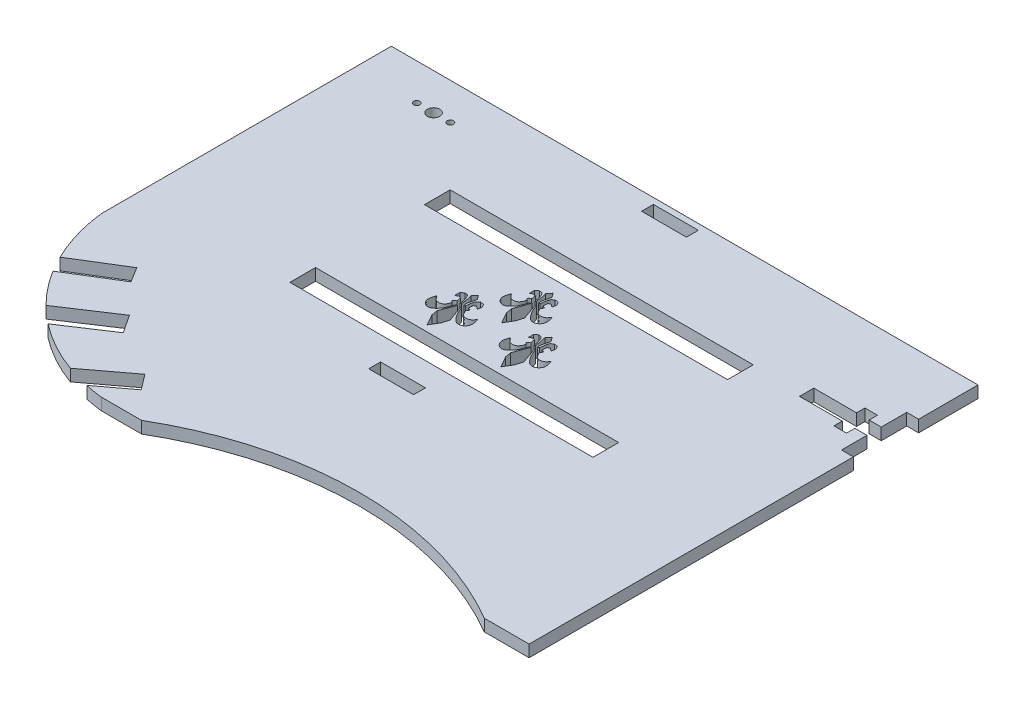
from build123d import *

# Parameters (mm, degrees)
SKETCH3_W               = 160
SKETCH3_H               = 120
BOSS_EXTRUDE1_DEPTH     = 3.175
SKETCH4_W               = 3.175
SKETCH4_H               = 17.435105301
CUT_EXTRUDE1_DEPTH      = 4.175
CUT_EXTRUDE2_DEPTH      = 4.175
SKETCH6_W               = 12
SKETCH6_H               = 3.175
CUT_EXTRUDE3_DEPTH      = 4.175
SKETCH8_W               = 3.17
SKETCH8_H               = 120
CUT_EXTRUDE4_DEPTH      = 4.175
SKETCH10_W              = 3.175
SKETCH10_H              = 3.175
CUT_EXTRUDE6_DEPTH      = 3.175
SKETCH11_W              = 3.175
SKETCH11_H              = 3.175
BOSS_EXTRUDE2_DEPTH     = 3.175
SKETCH14_W              = 12
SKETCH14_H              = 3.18
CUT_EXTRUDE8_DEPTH      = 4.175
CUT_EXTRUDE9_DEPTH      = 1
CUT_EXTRUDE9_DEPTH_BACK = 4.175
CUT_EXTRUDE10_DEPTH     = 3.18
CUT_EXTRUDE11_DEPTH     = 3.18
SKETCH22_W              = 81.025514908
SKETCH22_H              = 6.858687775
SKETCH22_H_2            = 6.86
CUT_EXTRUDE12_DEPTH     = 3.18
CUT_EXTRUDE13_DEPTH     = 3.18
SKETCH24_R              = 0.83
CUT_EXTRUDE14_DEPTH     = 10
SKETCH25_R              = 1.655978765
CUT_EXTRUDE15_DEPTH     = 80.772


with BuildPart() as part:
    # Sketch3 → Boss-Extrude1 (new body)
    with BuildSketch(Plane(origin=(0, 0, 0), x_dir=(1, 0, 0), z_dir=(0, 1, 0))):
        with Locations((80, -60)):
            Rectangle(SKETCH3_W, SKETCH3_H)
    extrude(amount=BOSS_EXTRUDE1_DEPTH)

    # Sketch4 → Cut-Extrude1 (cut, through all)
    with BuildSketch(Plane(origin=(0, 0, 0), x_dir=(-1, 0, 0), z_dir=(0, -1, 0))):
        with Locations((-158.4125, -24.593852358)):
            Rectangle(SKETCH4_W, SKETCH4_H)
    extrude(amount=-CUT_EXTRUDE1_DEPTH, mode=Mode.SUBTRACT)

    # Sketch5 → Cut-Extrude2 (cut, through all)
    with BuildSketch(Plane.XZ):
        Polygon((156.825, 26.498852357), (156.825, 22.688852357), (153.573768173, 22.688852357), (153.573768173, 20.453652357), (150.221, 20.453652357), (150.221, 22.688852357), (138.791, 22.688852357), (138.791, 26.498852357), (150.221, 26.498852357), (150.221, 28.734052357), (153.573768173, 28.734052357), (153.573768173, 26.498852357), align=None)
    extrude(amount=-CUT_EXTRUDE2_DEPTH, mode=Mode.SUBTRACT)

    # Sketch6 → Cut-Extrude3 (cut, through all)
    with BuildSketch(Plane(origin=(0, 3.175, 0), x_dir=(1, 0, 0), z_dir=(0, 1, 0))):
        with Locations((84, -3.177552545)):
            Rectangle(SKETCH6_W, SKETCH6_H)
    extrude(amount=-CUT_EXTRUDE3_DEPTH, mode=Mode.SUBTRACT)

    # Sketch8 → Cut-Extrude4 (cut, through all)
    with BuildSketch(Plane(origin=(0, 3.175, 0), x_dir=(1, 0, 0), z_dir=(0, 1, 0))):
        with Locations((1.585, -60)):
            Rectangle(SKETCH8_W, SKETCH8_H)
    extrude(amount=-CUT_EXTRUDE4_DEPTH, mode=Mode.SUBTRACT)

    # Sketch10 → Cut-Extrude6 (cut)
    with BuildSketch(Plane(origin=(0, 3.175, 0), x_dir=(1, 0, 0), z_dir=(0, 1, 0))):
        with Locations((76.4125, -3.177552545)):
            Rectangle(SKETCH10_W, SKETCH10_H)
    extrude(amount=-CUT_EXTRUDE6_DEPTH, mode=Mode.SUBTRACT)

    # Sketch11 → Boss-Extrude2 (add)
    with BuildSketch(Plane.ZY.offset(-90)):
        with Locations((3.177552545, 1.5875)):
            Rectangle(SKETCH11_W, SKETCH11_H)
    extrude(amount=BOSS_EXTRUDE2_DEPTH)

    # Sketch14 → Cut-Extrude8 (cut, through all)
    with BuildSketch(Plane(origin=(0, 3.175, 0), x_dir=(1, 0, 0), z_dir=(0, 1, 0))):
        with Locations((80.825, -76.121511289)):
            Rectangle(SKETCH14_W, SKETCH14_H)
    extrude(amount=-CUT_EXTRUDE8_DEPTH, mode=Mode.SUBTRACT)

    # Sketch18 → Cut-Extrude9 (cut, two sides)
    with BuildSketch(Plane(origin=(0, 3.175, 0), x_dir=(1, 0, 0), z_dir=(0, 1, 0))) as cut_extrude9_sk:
        with BuildLine():
            Line((3.17, -120), (45.627652889, -120))
            ThreePointArc((45.627652889, -120), (17.010977531, -106.159022469), (3.17, -77.542347111))
            Line((3.17, -77.542347111), (3.17, -120))
        make_face()
    extrude(amount=CUT_EXTRUDE9_DEPTH, mode=Mode.SUBTRACT)
    extrude(cut_extrude9_sk.sketch, amount=-CUT_EXTRUDE9_DEPTH_BACK, mode=Mode.SUBTRACT)

    # Sketch20 → Cut-Extrude10 (cut)
    with BuildSketch(Plane(origin=(0, 3.175, 0), x_dir=(1, 0, 0), z_dir=(0, 1, 0))):
        Polygon((10.011232474, -97.293572395), (22.920901511, -89.355856032), (20.42596132, -85.298158494), (7.516292283, -93.235874857), align=None)
        Polygon((17.010977531, -106.159022469), (30.452466209, -97.293572395), (33.670458106, -102.172580373), (20.228969428, -111.038030448), align=None)
        Polygon((34.806657091, -117.45740808), (46.189284418, -108.886802916), (49.274109143, -112.983761012), (37.891481816, -121.554366177), align=None)
    extrude(amount=-CUT_EXTRUDE10_DEPTH, mode=Mode.SUBTRACT)

    # Sketch21 → Cut-Extrude11 (cut)
    with BuildSketch(Plane(origin=(0, 3.175, 0), x_dir=(1, 0, 0), z_dir=(0, 1, 0))):
        with BuildLine():
            Line((481.322028139, -315.153099991), (148.033410765, -120))
            ThreePointArc((148.033410765, -120), (102.224970687, -107.57533056), (56.416530609, -120))
            Line((56.416530609, -120), (-276.872086765, -315.153099991))
            Line((-276.872086765, -315.153099991), (-276.872086765, -1087.593479327))
            Line((-276.872086765, -1087.593479327), (481.322028139, -1087.593479327))
            Line((481.322028139, -1087.593479327), (481.322028139, -315.153099991))
        make_face()
    extrude(amount=-CUT_EXTRUDE11_DEPTH, mode=Mode.SUBTRACT)

    # Sketch22 → Cut-Extrude12 (cut)
    with BuildSketch(Plane(origin=(0, 3.175, 0), x_dir=(1, 0, 0), z_dir=(0, 1, 0))):
        with Locations((84.792947212, -64.796382292)):
            Rectangle(SKETCH22_W, SKETCH22_H)
        with Locations((84.792947212, -28.821709785)):
            Rectangle(SKETCH22_W, SKETCH22_H_2)
    extrude(amount=-CUT_EXTRUDE12_DEPTH, mode=Mode.SUBTRACT)

    # Sketch23 → Cut-Extrude13 (cut)
    with BuildSketch(Plane(origin=(0, 3.175, 0), x_dir=(1, 0, 0), z_dir=(0, 1, 0))):
        with BuildLine():
            Line((92.040417593, -59.591635437), (90.350166764, -56.601191664))
            Line((90.350166764, -56.601191664), (90.090128175, -55.008455307))
            Line((90.090128175, -55.008455307), (91.552845238, -51.010362001))
            add(Edge.make_bspline(
                [(91.552845238, -51.010362001), (91.433660885, -51.064536707), (91.256267279, -51.057033429), (91.195292178, -51.172886119), (90.808267546, -51.90823292), (90.689834748, -52.774050109), (90.252652294, -53.480728597), (89.885655321, -54.073956579), (89.392536165, -54.606464459), (88.822440054, -55.008455307), (88.513150163, -55.226544333), (88.088992408, -55.339557317), (87.717276051, -55.268493896), (87.291986987, -55.187188633), (86.882599473, -54.924001881), (86.612112048, -54.5858926), (86.331646339, -54.235310464), (86.167019037, -53.767057858), (86.157044517, -53.318204478), (86.14443269, -52.750672253), (86.417083106, -52.213040475), (86.547102401, -51.660458474)],
                knots=[0, 0, 0, 0, 1, 1, 1, 2, 2, 2, 3, 3, 3, 4, 4, 4, 5, 5, 5, 6, 6, 6, 7, 7, 7, 7], degree=3))
            Line((86.547102401, -51.660458474), (86.677121695, -51.62795365))
            add(Edge.make_bspline(
                [(86.677121695, -51.62795365), (87.002169931, -51.98550671), (87.221318587, -52.482016111), (87.652266404, -52.70061283), (88.029614545, -52.892021307), (88.517953599, -52.897622781), (88.919954525, -52.765622477), (89.299585453, -52.640967545), (89.600138024, -52.312279983), (89.830089586, -51.98550671), (90.027271425, -51.70530094), (90.046788411, -51.335410238), (90.155137823, -51.010362001)],
                knots=[0, 0, 0, 0, 1, 1, 1, 2, 2, 2, 3, 3, 3, 4, 4, 4, 4], degree=3))
            Line((90.155137823, -51.010362001), (89.732575116, -50.587799294))
            add(Edge.make_bspline(
                [(89.732575116, -50.587799294), (89.851759469, -50.446945059), (89.941747705, -50.274909108), (90.090128175, -50.165236587), (90.200342422, -50.083773884), (90.350166764, -50.078557058), (90.480186059, -50.035217293)],
                knots=[0, 0, 0, 0, 1, 1, 1, 2, 2, 2, 2], degree=3))
            Line((90.480186059, -50.035217293), (90.252652294, -48.832538819))
            add(Edge.make_bspline(
                [(90.252652294, -48.832538819), (90.003448646, -48.800033995), (89.746686344, -48.665982921), (89.50504135, -48.735024348), (89.252846931, -48.807079896), (89.093313584, -49.060072584), (88.887449701, -49.222596702)],
                knots=[0, 0, 0, 0, 1, 1, 1, 2, 2, 2, 2], degree=3))
            Line((88.887449701, -49.222596702), (88.919954525, -47.694869992))
            Line((88.919954525, -47.694869992), (89.700070292, -47.109783167))
            add(Edge.make_bspline(
                [(89.700070292, -47.109783167), (89.970943822, -47.174792814), (90.315715346, -47.107836573), (90.512690882, -47.304812109), (90.84848667, -47.640607896), (91.014153381, -48.121472998), (91.162787355, -48.57250023), (91.331736227, -49.085172668), (91.357816297, -49.634324468), (91.455330767, -50.165236587)],
                knots=[0, 0, 0, 0, 1, 1, 1, 2, 2, 2, 3, 3, 3, 3], degree=3))
            Line((91.455330767, -50.165236587), (91.715369356, -50.035217293))
            add(Edge.make_bspline(
                [(91.715369356, -50.035217293), (91.639524768, -49.450130468), (91.591760514, -48.860713741), (91.487835591, -48.279956817), (91.407290454, -47.829851641), (91.271136767, -47.391491638), (91.162787355, -46.947259049)],
                knots=[0, 0, 0, 0, 1, 1, 1, 2, 2, 2, 2], degree=3))
            Line((91.162787355, -46.947259049), (92.040417593, -45.874599869))
            Line((92.040417593, -45.874599869), (92.885543007, -46.979763872))
            add(Edge.make_bspline(
                [(92.885543007, -46.979763872), (92.777193595, -47.445666344), (92.671877484, -47.912284659), (92.560494771, -48.377471288), (92.487677503, -48.681590463), (92.349992883, -48.975355261), (92.332961005, -49.287606349), (92.316853875, -49.582903731), (92.419640535, -49.872693175), (92.4629803, -50.165236587)],
                knots=[0, 0, 0, 0, 1, 1, 1, 2, 2, 2, 3, 3, 3, 3], degree=3))
            Line((92.4629803, -50.165236587), (92.755523712, -50.035217293))
            add(Edge.make_bspline(
                [(92.755523712, -50.035217293), (92.885543007, -49.309276232), (92.875677077, -48.543722743), (93.145581596, -47.85739411), (93.271788678, -47.536467529), (93.643988891, -47.380656697), (93.893192539, -47.14228799)],
                knots=[0, 0, 0, 0, 1, 1, 1, 2, 2, 2, 2], degree=3))
            Line((93.893192539, -47.14228799), (94.8033276, -47.272307285))
            add(Edge.make_bspline(
                [(94.8033276, -47.272307285), (94.955016777, -47.564850698), (95.209512224, -47.824051475), (95.258395131, -48.149937523), (95.31204007, -48.507570449), (95.150045719, -48.865043642), (95.095871013, -49.222596702)],
                knots=[0, 0, 0, 0, 1, 1, 1, 2, 2, 2, 2], degree=3))
            Line((95.095871013, -49.222596702), (94.34826007, -48.670014701))
            Line((94.34826007, -48.670014701), (93.763173245, -48.93005329))
            Line((93.763173245, -48.93005329), (93.665658774, -50.165236587))
            Line((93.665658774, -50.165236587), (94.283250422, -50.392770353))
            add(Edge.make_bspline(
                [(94.283250422, -50.392770353), (94.229075716, -50.566129412), (94.207232046, -50.753144622), (94.120726304, -50.91284753), (94.062341913, -51.0206341), (93.947367245, -51.08620659), (93.860687715, -51.172886119)],
                knots=[0, 0, 0, 0, 1, 1, 1, 2, 2, 2, 2], degree=3))
            add(Edge.make_bspline(
                [(93.860687715, -51.172886119), (94.153231128, -51.62795365), (94.329041742, -52.18430758), (94.738317953, -52.538088712), (95.010799127, -52.773623286), (95.418483529, -52.842060339), (95.778472309, -52.830632124), (96.134694899, -52.81932347), (96.492114255, -52.674528706), (96.786121841, -52.473079064), (97.096390872, -52.260487321), (97.284529137, -51.909662122), (97.533732785, -51.62795365)],
                knots=[0, 0, 0, 0, 1, 1, 1, 2, 2, 2, 3, 3, 3, 4, 4, 4, 4], degree=3))
            add(Edge.make_bspline(
                [(97.533732785, -51.62795365), (97.663752079, -52.234710358), (97.950172367, -52.828253834), (97.923790668, -53.448223773), (97.904797811, -53.894555923), (97.710793086, -54.358945611), (97.40371349, -54.68340707), (97.097266769, -55.007199832), (96.645352124, -55.231974681), (96.201035016, -55.268493896), (95.791259692, -55.302174059), (95.346074128, -55.142426701), (95.030861366, -54.878436012), (94.445792267, -54.388440642), (93.991666711, -53.746038214), (93.600649126, -53.090670713), (93.215028431, -52.444348702), (93.015562301, -51.703798239), (92.723018889, -51.010362001)],
                knots=[0, 0, 0, 0, 1, 1, 1, 2, 2, 2, 3, 3, 3, 4, 4, 4, 5, 5, 5, 6, 6, 6, 6], degree=3))
            Line((92.723018889, -51.010362001), (92.495485123, -51.140381296))
            Line((92.495485123, -51.140381296), (93.99070701, -55.39851319))
            Line((93.99070701, -55.39851319), (93.405620185, -57.316297784))
            Line((93.405620185, -57.316297784), (92.040417593, -59.591635437))
        make_face()
        with BuildLine():
            Line((72.472458803, -59.743861952), (70.782207974, -56.753418179))
            Line((70.782207974, -56.753418179), (70.522169385, -55.160681822))
            Line((70.522169385, -55.160681822), (71.984886448, -51.162588516))
            add(Edge.make_bspline(
                [(71.984886448, -51.162588516), (71.865702095, -51.216763223), (71.688308489, -51.209259944), (71.627333388, -51.325112635), (71.240308756, -52.060459436), (71.121875958, -52.926276624), (70.684693503, -53.632955112), (70.317696531, -54.226183094), (69.824577375, -54.758690975), (69.254481264, -55.160681822), (68.945191373, -55.378770848), (68.521033618, -55.491783832), (68.149317261, -55.420720411), (67.724028197, -55.339415149), (67.314640683, -55.076228396), (67.044153258, -54.738119115), (66.763687549, -54.387536979), (66.599060247, -53.919284374), (66.589085727, -53.470430994), (66.5764739, -52.902898768), (66.849124316, -52.36526699), (66.979143611, -51.812684989)],
                knots=[0, 0, 0, 0, 1, 1, 1, 2, 2, 2, 3, 3, 3, 4, 4, 4, 5, 5, 5, 6, 6, 6, 7, 7, 7, 7], degree=3))
            Line((66.979143611, -51.812684989), (67.109162905, -51.780180165))
            add(Edge.make_bspline(
                [(67.109162905, -51.780180165), (67.434211141, -52.137733225), (67.653359797, -52.634242626), (68.084307614, -52.852839345), (68.461655755, -53.044247822), (68.949994809, -53.049849296), (69.351995735, -52.917848992), (69.731626663, -52.79319406), (70.032179234, -52.464506498), (70.262130796, -52.137733225), (70.459312635, -51.857527455), (70.478829621, -51.487636753), (70.587179033, -51.162588516)],
                knots=[0, 0, 0, 0, 1, 1, 1, 2, 2, 2, 3, 3, 3, 4, 4, 4, 4], degree=3))
            Line((70.587179033, -51.162588516), (70.164616326, -50.740025809))
            add(Edge.make_bspline(
                [(70.164616326, -50.740025809), (70.283800679, -50.599171574), (70.373788915, -50.427135624), (70.522169385, -50.317463102), (70.632383632, -50.236000399), (70.782207974, -50.230783573), (70.912227269, -50.187443808)],
                knots=[0, 0, 0, 0, 1, 1, 1, 2, 2, 2, 2], degree=3))
            Line((70.912227269, -50.187443808), (70.684693503, -48.984765334))
            add(Edge.make_bspline(
                [(70.684693503, -48.984765334), (70.435489856, -48.95226051), (70.178727554, -48.818209436), (69.93708256, -48.887250863), (69.684888141, -48.959306411), (69.525354794, -49.212299099), (69.319490911, -49.374823217)],
                knots=[0, 0, 0, 0, 1, 1, 1, 2, 2, 2, 2], degree=3))
            Line((69.319490911, -49.374823217), (69.351995735, -47.847096507))
            Line((69.351995735, -47.847096507), (70.132111502, -47.262009682))
            add(Edge.make_bspline(
                [(70.132111502, -47.262009682), (70.402985032, -47.327019329), (70.747756556, -47.260063088), (70.944732092, -47.457038624), (71.28052788, -47.792834411), (71.446194591, -48.273699513), (71.594828565, -48.724726745), (71.763777437, -49.237399183), (71.789857507, -49.786550983), (71.887371977, -50.317463102)],
                knots=[0, 0, 0, 0, 1, 1, 1, 2, 2, 2, 3, 3, 3, 3], degree=3))
            Line((71.887371977, -50.317463102), (72.147410566, -50.187443808))
            add(Edge.make_bspline(
                [(72.147410566, -50.187443808), (72.071565978, -49.602356983), (72.023801724, -49.012940256), (71.919876801, -48.432183332), (71.839331664, -47.982078156), (71.703177977, -47.543718153), (71.594828565, -47.099485564)],
                knots=[0, 0, 0, 0, 1, 1, 1, 2, 2, 2, 2], degree=3))
            Line((71.594828565, -47.099485564), (72.472458803, -46.026826384))
            Line((72.472458803, -46.026826384), (73.317584217, -47.131990388))
            add(Edge.make_bspline(
                [(73.317584217, -47.131990388), (73.209234805, -47.597892859), (73.103918694, -48.064511175), (72.992535981, -48.529697803), (72.919718713, -48.833816978), (72.782034093, -49.127581776), (72.765002215, -49.439832865), (72.748895085, -49.735130247), (72.851681745, -50.02491969), (72.89502151, -50.317463102)],
                knots=[0, 0, 0, 0, 1, 1, 1, 2, 2, 2, 3, 3, 3, 3], degree=3))
            Line((72.89502151, -50.317463102), (73.187564922, -50.187443808))
            add(Edge.make_bspline(
                [(73.187564922, -50.187443808), (73.317584217, -49.461502747), (73.307718287, -48.695949258), (73.577622806, -48.009620625), (73.703829888, -47.688694044), (74.076030101, -47.532883212), (74.325233749, -47.294514506)],
                knots=[0, 0, 0, 0, 1, 1, 1, 2, 2, 2, 2], degree=3))
            Line((74.325233749, -47.294514506), (75.23536881, -47.4245338))
            add(Edge.make_bspline(
                [(75.23536881, -47.4245338), (75.387057987, -47.717077213), (75.641553434, -47.97627799), (75.690436341, -48.302164038), (75.74408128, -48.659796964), (75.582086929, -49.017270158), (75.527912223, -49.374823217)],
                knots=[0, 0, 0, 0, 1, 1, 1, 2, 2, 2, 2], degree=3))
            Line((75.527912223, -49.374823217), (74.78030128, -48.822241216))
            Line((74.78030128, -48.822241216), (74.195214455, -49.082279805))
            Line((74.195214455, -49.082279805), (74.097699984, -50.317463102))
            Line((74.097699984, -50.317463102), (74.715291632, -50.544996868))
            add(Edge.make_bspline(
                [(74.715291632, -50.544996868), (74.661116926, -50.718355927), (74.639273256, -50.905371138), (74.552767514, -51.065074046), (74.494383123, -51.172860615), (74.379408455, -51.238433105), (74.292728925, -51.325112635)],
                knots=[0, 0, 0, 0, 1, 1, 1, 2, 2, 2, 2], degree=3))
            add(Edge.make_bspline(
                [(74.292728925, -51.325112635), (74.585272338, -51.780180165), (74.761082952, -52.336534095), (75.170359163, -52.690315227), (75.442840337, -52.925849801), (75.850524739, -52.994286854), (76.210513519, -52.982858639), (76.566736109, -52.971549986), (76.924155465, -52.826755222), (77.218163051, -52.625305579), (77.528432082, -52.412713836), (77.716570347, -52.061888637), (77.965773995, -51.780180165)],
                knots=[0, 0, 0, 0, 1, 1, 1, 2, 2, 2, 3, 3, 3, 4, 4, 4, 4], degree=3))
            add(Edge.make_bspline(
                [(77.965773995, -51.780180165), (78.095793289, -52.386936873), (78.382213577, -52.980480349), (78.355831878, -53.600450288), (78.336839021, -54.046782438), (78.142834296, -54.511172126), (77.8357547, -54.835633586), (77.529307979, -55.159426347), (77.077393334, -55.384201196), (76.633076226, -55.420720411), (76.223300902, -55.454400574), (75.778115338, -55.294653216), (75.462902576, -55.030662527), (74.877833477, -54.540667157), (74.423707921, -53.898264729), (74.032690336, -53.242897228), (73.647069641, -52.596575217), (73.447603511, -51.856024754), (73.155060099, -51.162588516)],
                knots=[0, 0, 0, 0, 1, 1, 1, 2, 2, 2, 3, 3, 3, 4, 4, 4, 5, 5, 5, 6, 6, 6, 6], degree=3))
            Line((73.155060099, -51.162588516), (72.927526333, -51.292607811))
            Line((72.927526333, -51.292607811), (74.42274822, -55.550739705))
            Line((74.42274822, -55.550739705), (73.837661395, -57.468524299))
            Line((73.837661395, -57.468524299), (72.472458803, -59.743861952))
        make_face()
        with BuildLine():
            Line((81.965210871, -49.28764759), (80.274960043, -46.297203817))
            Line((80.274960043, -46.297203817), (80.014921454, -44.70446746))
            Line((80.014921454, -44.70446746), (81.477638517, -40.706374154))
            add(Edge.make_bspline(
                [(81.477638517, -40.706374154), (81.358454164, -40.76054886), (81.181060558, -40.753045582), (81.120085457, -40.868898272), (80.733060825, -41.604245073), (80.614628027, -42.470062262), (80.177445572, -43.176740749), (79.8104486, -43.769968732), (79.317329444, -44.302476612), (78.747233333, -44.70446746), (78.437943442, -44.922556486), (78.013785687, -45.03556947), (77.64206933, -44.964506049), (77.216780266, -44.883200786), (76.807392752, -44.620014034), (76.536905327, -44.281904752), (76.256439618, -43.931322617), (76.091812316, -43.463070011), (76.081837796, -43.014216631), (76.069225969, -42.446684406), (76.341876385, -41.909052628), (76.47189568, -41.356470627)],
                knots=[0, 0, 0, 0, 1, 1, 1, 2, 2, 2, 3, 3, 3, 4, 4, 4, 5, 5, 5, 6, 6, 6, 7, 7, 7, 7], degree=3))
            Line((76.47189568, -41.356470627), (76.601914974, -41.323965803))
            add(Edge.make_bspline(
                [(76.601914974, -41.323965803), (76.92696321, -41.681518863), (77.146111866, -42.178028264), (77.577059683, -42.396624982), (77.954407824, -42.58803346), (78.442746877, -42.593634934), (78.844747804, -42.46163463), (79.224378732, -42.336979698), (79.524931303, -42.008292136), (79.754882865, -41.681518863), (79.952064704, -41.401313093), (79.971581689, -41.03142239), (80.079931101, -40.706374154)],
                knots=[0, 0, 0, 0, 1, 1, 1, 2, 2, 2, 3, 3, 3, 4, 4, 4, 4], degree=3))
            Line((80.079931101, -40.706374154), (79.657368394, -40.283811447))
            add(Edge.make_bspline(
                [(79.657368394, -40.283811447), (79.776552748, -40.142957211), (79.866540984, -39.970921261), (80.014921454, -39.86124874), (80.1251357, -39.779786036), (80.274960043, -39.77456921), (80.404979338, -39.731229446)],
                knots=[0, 0, 0, 0, 1, 1, 1, 2, 2, 2, 2], degree=3))
            Line((80.404979338, -39.731229446), (80.177445572, -38.528550972))
            add(Edge.make_bspline(
                [(80.177445572, -38.528550972), (79.928241925, -38.496046148), (79.671479623, -38.361995074), (79.429834629, -38.431036501), (79.17764021, -38.503092049), (79.018106863, -38.756084737), (78.81224298, -38.918608855)],
                knots=[0, 0, 0, 0, 1, 1, 1, 2, 2, 2, 2], degree=3))
            Line((78.81224298, -38.918608855), (78.844747804, -37.390882145))
            Line((78.844747804, -37.390882145), (79.624863571, -36.80579532))
            add(Edge.make_bspline(
                [(79.624863571, -36.80579532), (79.895737101, -36.870804967), (80.240508625, -36.803848725), (80.437484161, -37.000824261), (80.773279949, -37.336620049), (80.93894666, -37.817485151), (81.087580634, -38.268512383), (81.256529505, -38.781184821), (81.282609575, -39.330336621), (81.380124046, -39.86124874)],
                knots=[0, 0, 0, 0, 1, 1, 1, 2, 2, 2, 3, 3, 3, 3], degree=3))
            Line((81.380124046, -39.86124874), (81.640162635, -39.731229446))
            add(Edge.make_bspline(
                [(81.640162635, -39.731229446), (81.564318047, -39.14614262), (81.516553793, -38.556725894), (81.41262887, -37.97596897), (81.332083733, -37.525863794), (81.195930046, -37.087503791), (81.087580634, -36.643271202)],
                knots=[0, 0, 0, 0, 1, 1, 1, 2, 2, 2, 2], degree=3))
            Line((81.087580634, -36.643271202), (81.965210871, -35.570612022))
            Line((81.965210871, -35.570612022), (82.810336286, -36.675776025))
            add(Edge.make_bspline(
                [(82.810336286, -36.675776025), (82.701986874, -37.141678497), (82.596670763, -37.608296812), (82.485288049, -38.073483441), (82.412470782, -38.377602616), (82.274786162, -38.671367414), (82.257754284, -38.983618502), (82.241647154, -39.278915884), (82.344433814, -39.568705327), (82.387773579, -39.86124874)],
                knots=[0, 0, 0, 0, 1, 1, 1, 2, 2, 2, 3, 3, 3, 3], degree=3))
            Line((82.387773579, -39.86124874), (82.680316991, -39.731229446))
            add(Edge.make_bspline(
                [(82.680316991, -39.731229446), (82.810336286, -39.005288385), (82.800470356, -38.239734895), (83.070374875, -37.553406263), (83.196581957, -37.232479682), (83.56878217, -37.07666885), (83.817985818, -36.838300143)],
                knots=[0, 0, 0, 0, 1, 1, 1, 2, 2, 2, 2], degree=3))
            Line((83.817985818, -36.838300143), (84.728120879, -36.968319438))
            add(Edge.make_bspline(
                [(84.728120879, -36.968319438), (84.879810056, -37.26086285), (85.134305503, -37.520063628), (85.18318841, -37.845949676), (85.236833349, -38.203582602), (85.074838998, -38.561055795), (85.020664292, -38.918608855)],
                knots=[0, 0, 0, 0, 1, 1, 1, 2, 2, 2, 2], degree=3))
            Line((85.020664292, -38.918608855), (84.273053349, -38.366026854))
            Line((84.273053349, -38.366026854), (83.687966523, -38.626065442))
            Line((83.687966523, -38.626065442), (83.590452053, -39.86124874))
            Line((83.590452053, -39.86124874), (84.208043701, -40.088782505))
            add(Edge.make_bspline(
                [(84.208043701, -40.088782505), (84.153868995, -40.262141565), (84.132025325, -40.449156775), (84.045519583, -40.608859683), (83.987135191, -40.716646253), (83.872160524, -40.782218743), (83.785480994, -40.868898272)],
                knots=[0, 0, 0, 0, 1, 1, 1, 2, 2, 2, 2], degree=3))
            add(Edge.make_bspline(
                [(83.785480994, -40.868898272), (84.078024407, -41.323965803), (84.253835021, -41.880319733), (84.663111232, -42.234100864), (84.935592406, -42.469635439), (85.343276808, -42.538072492), (85.703265588, -42.526644277), (86.059488177, -42.515335623), (86.416907534, -42.370540859), (86.71091512, -42.169091217), (87.021184151, -41.956499474), (87.209322416, -41.605674274), (87.458526063, -41.323965803)],
                knots=[0, 0, 0, 0, 1, 1, 1, 2, 2, 2, 3, 3, 3, 4, 4, 4, 4], degree=3))
            add(Edge.make_bspline(
                [(87.458526063, -41.323965803), (87.588545358, -41.930722511), (87.874965646, -42.524265987), (87.848583947, -43.144235926), (87.829591089, -43.590568076), (87.635586364, -44.054957764), (87.328506769, -44.379419223), (87.022060048, -44.703211985), (86.570145402, -44.927986834), (86.125828295, -44.964506049), (85.716052971, -44.998186212), (85.270867407, -44.838438854), (84.955654645, -44.574448165), (84.370585546, -44.084452795), (83.91645999, -43.442050367), (83.525442405, -42.786682866), (83.139821709, -42.140360855), (82.94035558, -41.399810391), (82.647812168, -40.706374154)],
                knots=[0, 0, 0, 0, 1, 1, 1, 2, 2, 2, 3, 3, 3, 4, 4, 4, 5, 5, 5, 6, 6, 6, 6], degree=3))
            Line((82.647812168, -40.706374154), (82.420278402, -40.836393449))
            Line((82.420278402, -40.836393449), (83.915500289, -45.094525343))
            Line((83.915500289, -45.094525343), (83.330413464, -47.012309937))
            Line((83.330413464, -47.012309937), (81.965210871, -49.28764759))
        make_face()
    extrude(amount=-CUT_EXTRUDE13_DEPTH, mode=Mode.SUBTRACT)

    # Sketch24 → Cut-Extrude14 (cut)
    with BuildSketch(Plane(origin=(0, 3.175, 0), x_dir=(1, 0, 0), z_dir=(0, 1, 0))):
        with Locations((28.725114957, -9.77)):
            Circle(SKETCH24_R)
        with Locations((19.725114957, -9.77)):
            Circle(SKETCH24_R)
    extrude(amount=-CUT_EXTRUDE14_DEPTH, mode=Mode.SUBTRACT)

    # Sketch25 → Cut-Extrude15 (cut)
    with BuildSketch(Plane(origin=(0, 3.175, 0), x_dir=(1, 0, 0), z_dir=(0, 1, 0))):
        with Locations((24.225114957, -9.77)):
            Circle(SKETCH25_R)
    extrude(amount=-CUT_EXTRUDE15_DEPTH, mode=Mode.SUBTRACT)


solid = part.part
